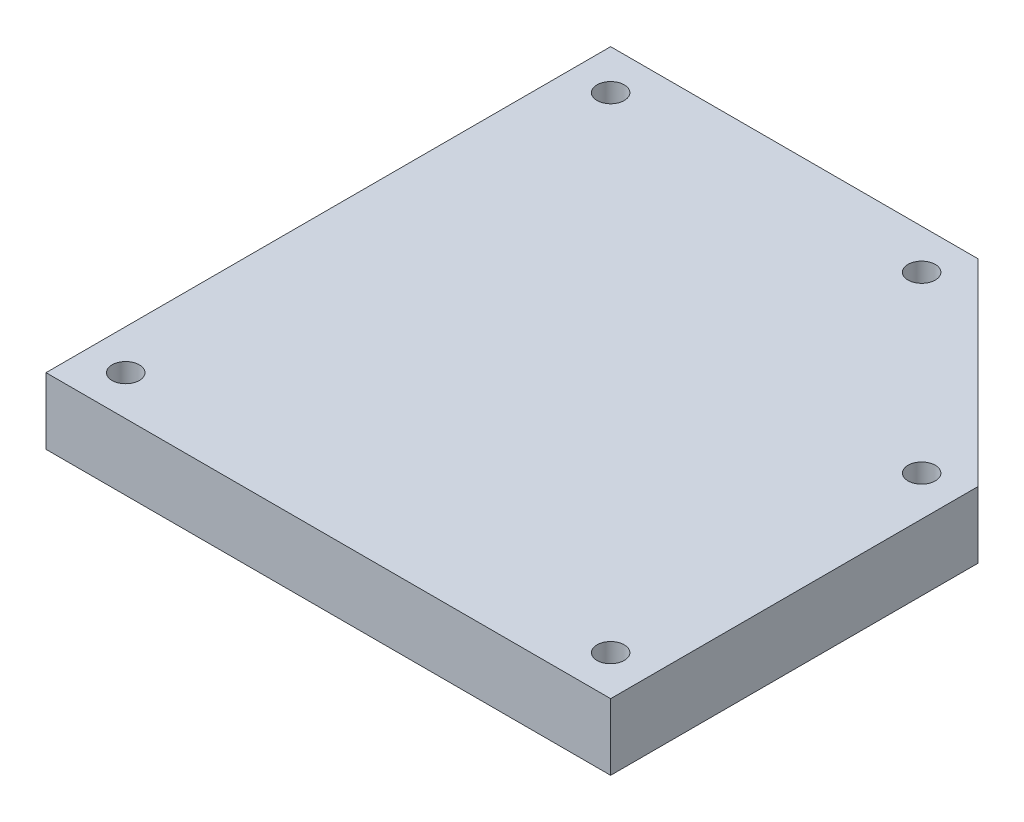
from build123d import *

# Parameters (mm, degrees)
BOSS_EXTRUDE1_DEPTH = 10
CUT_EXTRUDE3_REACH  = 12
SKETCH2_R           = 2.05
SKETCH5_R           = 4
CUT_EXTRUDE4_DEPTH  = 5


with BuildPart() as part:
    # Sketch1 → Boss-Extrude1 (new body)
    with BuildSketch(Plane(origin=(0, 0, 0), x_dir=(1, 0, 0), z_dir=(0, 1, 0))):
        Polygon((-41.160131748, 19.796063365), (-41.160131748, -65.203936635), (43.839868252, -65.203936635), (43.839868252, -9.902421445), (14.141383442, 19.796063365), align=None)
    extrude(amount=BOSS_EXTRUDE1_DEPTH)

    # Sketch2 → Cut-Extrude3 (cut, up to next)
    with BuildSketch(Plane(origin=(0, 10, 0), x_dir=(1, 0, 0), z_dir=(0, 1, 0)), mode=Mode.PRIVATE) as cut_extrude3_sk1:
        with Locations((37.839868252, -12.387702819)):
            Circle(SKETCH2_R)
    cut_extrude3_tool1 = extrude(cut_extrude3_sk1.sketch, amount=-CUT_EXTRUDE3_REACH, mode=Mode.PRIVATE) & part.part
    add(cut_extrude3_tool1.solids().sort_by_distance((37.839868, 10, 12.387703))[0], mode=Mode.SUBTRACT)
    # Sketch2 → Cut-Extrude3 (cut, up to next)
    with BuildSketch(Plane(origin=(0, 10, 0), x_dir=(1, 0, 0), z_dir=(0, 1, 0)), mode=Mode.PRIVATE) as cut_extrude3_sk2:
        with Locations((37.839868252, -59.203936635)):
            Circle(SKETCH2_R)
    cut_extrude3_tool2 = extrude(cut_extrude3_sk2.sketch, amount=-CUT_EXTRUDE3_REACH, mode=Mode.PRIVATE) & part.part
    add(cut_extrude3_tool2.solids().sort_by_distance((37.839868, 10, 59.203937))[0], mode=Mode.SUBTRACT)
    # Sketch2 → Cut-Extrude3 (cut, up to next)
    with BuildSketch(Plane(origin=(0, 10, 0), x_dir=(1, 0, 0), z_dir=(0, 1, 0)), mode=Mode.PRIVATE) as cut_extrude3_sk3:
        with Locations((-35.160131748, -59.203936635)):
            Circle(SKETCH2_R)
    cut_extrude3_tool3 = extrude(cut_extrude3_sk3.sketch, amount=-CUT_EXTRUDE3_REACH, mode=Mode.PRIVATE) & part.part
    add(cut_extrude3_tool3.solids().sort_by_distance((-35.160132, 10, 59.203937))[0], mode=Mode.SUBTRACT)
    # Sketch2 → Cut-Extrude3 (cut, up to next)
    with BuildSketch(Plane(origin=(0, 10, 0), x_dir=(1, 0, 0), z_dir=(0, 1, 0)), mode=Mode.PRIVATE) as cut_extrude3_sk4:
        with Locations((-35.160131748, 13.796063365)):
            Circle(SKETCH2_R)
    cut_extrude3_tool4 = extrude(cut_extrude3_sk4.sketch, amount=-CUT_EXTRUDE3_REACH, mode=Mode.PRIVATE) & part.part
    add(cut_extrude3_tool4.solids().sort_by_distance((-35.160132, 10, -13.796063))[0], mode=Mode.SUBTRACT)
    # Sketch2 → Cut-Extrude3 (cut, up to next)
    with BuildSketch(Plane(origin=(0, 10, 0), x_dir=(1, 0, 0), z_dir=(0, 1, 0)), mode=Mode.PRIVATE) as cut_extrude3_sk5:
        with Locations((11.656102068, 13.796063365)):
            Circle(SKETCH2_R)
    cut_extrude3_tool5 = extrude(cut_extrude3_sk5.sketch, amount=-CUT_EXTRUDE3_REACH, mode=Mode.PRIVATE) & part.part
    add(cut_extrude3_tool5.solids().sort_by_distance((11.656102, 10, -13.796063))[0], mode=Mode.SUBTRACT)

    # Sketch5 → Cut-Extrude4 (cut)
    with BuildSketch(Plane.XZ):
        with Locations((37.839868252, 59.203936635)):
            Circle(SKETCH5_R)
        with Locations((37.839868252, 12.387702819)):
            Circle(SKETCH5_R)
        with Locations((11.656102068, -13.796063365)):
            Circle(SKETCH5_R)
        with Locations((-35.160131748, -13.796063365)):
            Circle(SKETCH5_R)
        with Locations((-35.160131748, 59.203936635)):
            Circle(SKETCH5_R)
    extrude(amount=-CUT_EXTRUDE4_DEPTH, mode=Mode.SUBTRACT)


solid = part.part
